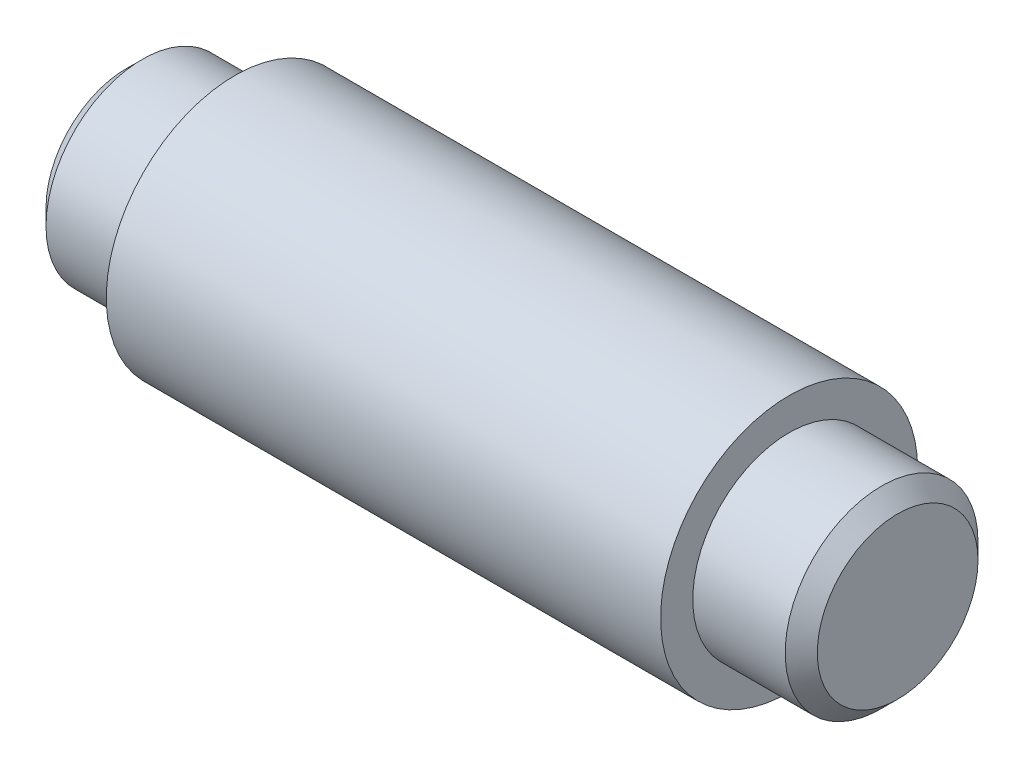
from build123d import *

# Parameters (mm, degrees)
CHAMFER1_SIZE = 1.5875
CHAMFER2_SIZE = 1.5875


with BuildPart() as part:
    # Sketch1 → Revolve1 (revolve)
    with BuildSketch(Plane.XY):
        Polygon((0, 0), (0, 9.525), (10.7188, 9.525), (10.7188, 12.7), (65.4812, 12.7), (65.4812, 9.525), (76.2, 9.525), (76.2, 0), align=None)
    revolve(axis=Axis((76.2, 0, 0), (-1, 0, 0)))

    # Chamfer1
    chamfer1_edges = [part.edges().sort_by_distance(p)[0] for p in [
        (76.2, -9.525, 0),
    ]]
    chamfer(chamfer1_edges, length=CHAMFER1_SIZE)

    # Chamfer2
    chamfer2_edges = [part.edges().sort_by_distance(p)[0] for p in [
        (0, -9.525, 0),
    ]]
    chamfer(chamfer2_edges, length=CHAMFER2_SIZE)


solid = part.part
